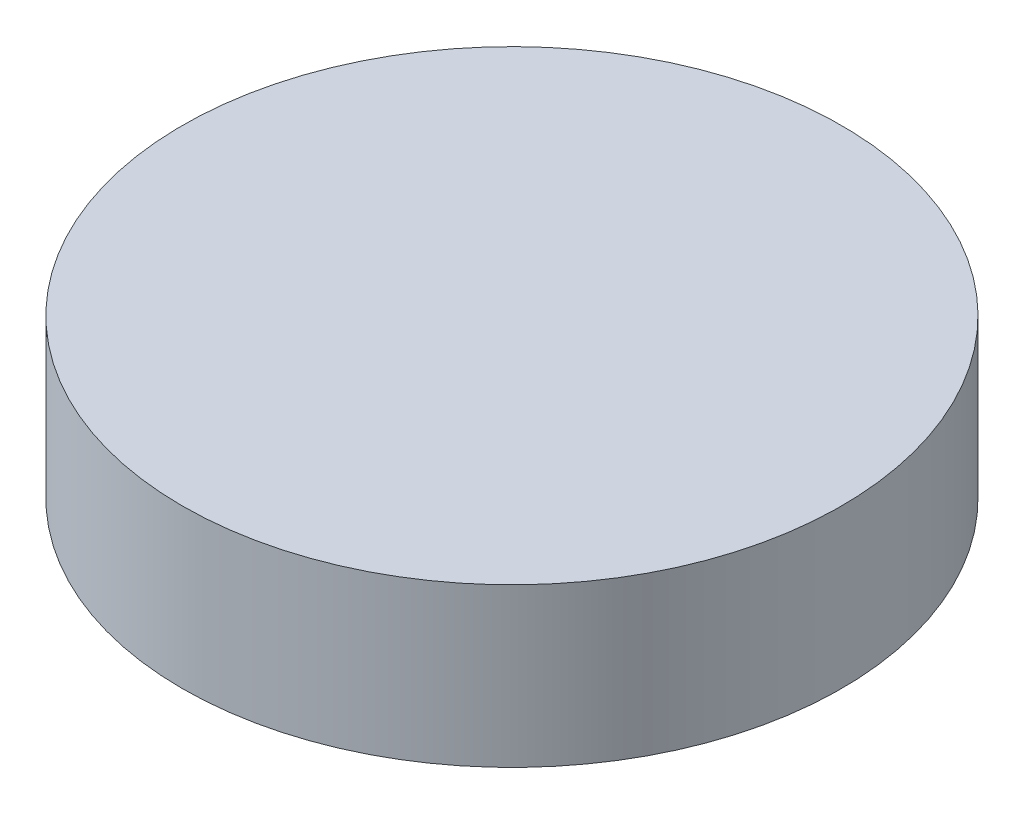
from build123d import *

# Parameters (mm, degrees)
CROQUIS1_R              = 12.5
SALIENTE_EXTRUIR1_DEPTH = 6


with BuildPart() as part:
    # Croquis1 → Saliente-Extruir1 (new body)
    with BuildSketch(Plane(origin=(0, 0, 0), x_dir=(1, 0, 0), z_dir=(0, 1, 0))):
        Circle(CROQUIS1_R)
    extrude(amount=SALIENTE_EXTRUIR1_DEPTH)


solid = part.part
